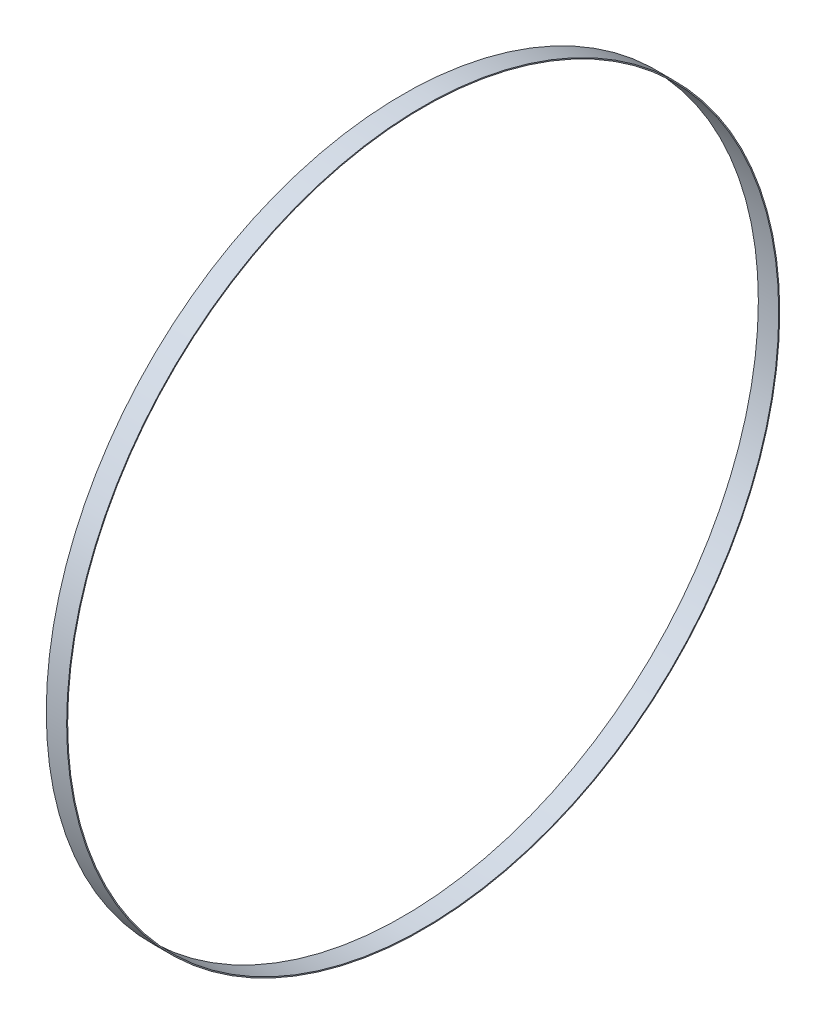
from build123d import *

# Parameters (mm, degrees)
SKETCH1_R           = 17.5
SKETCH1_R_2         = 17.45
BOSS_EXTRUDE1_DEPTH = 1


with BuildPart() as part:
    # Sketch1 → Boss-Extrude1 (new body)
    with BuildSketch(Plane(origin=(0, 0, 0), x_dir=(0, 0, -1), z_dir=(1, 0, 0))):
        Circle(SKETCH1_R)
        Circle(SKETCH1_R_2, mode=Mode.SUBTRACT)
    extrude(amount=BOSS_EXTRUDE1_DEPTH)


solid = part.part
